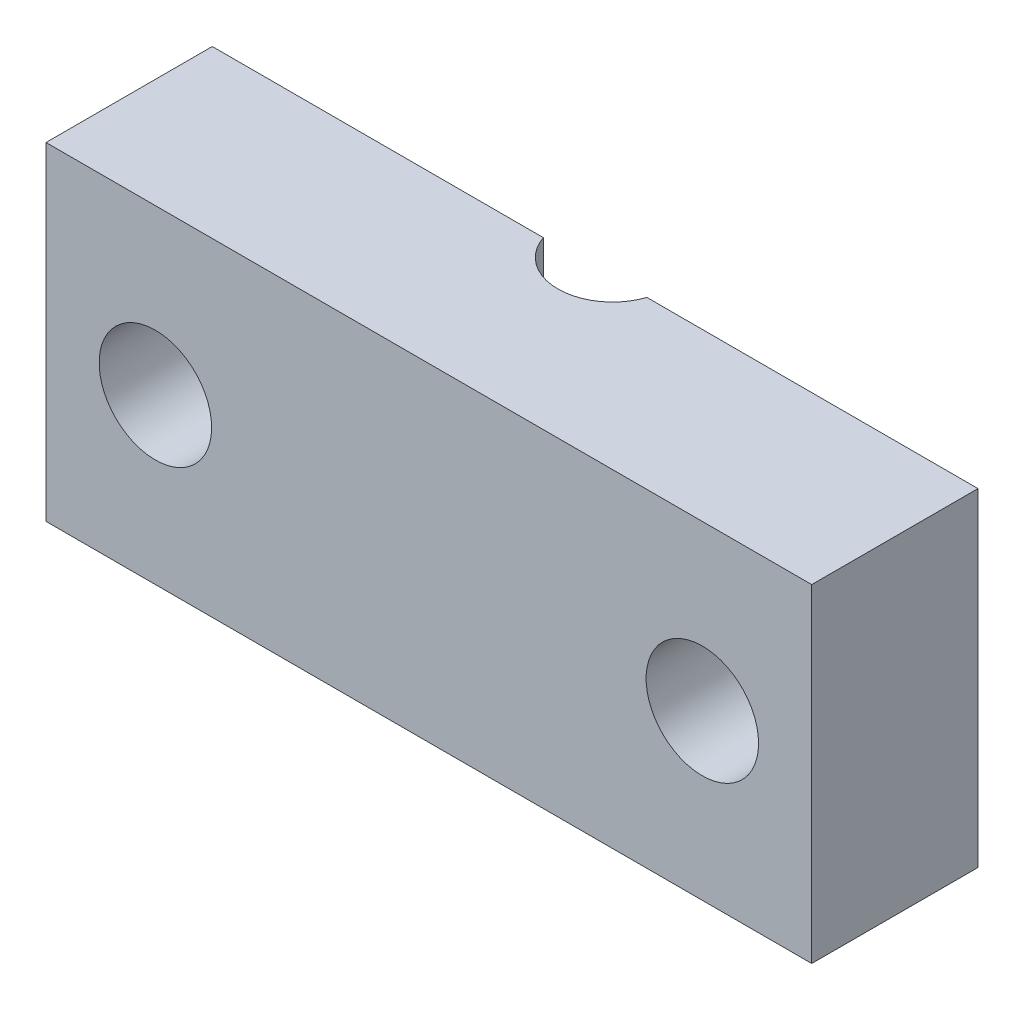
from build123d import *

# Parameters (mm, degrees)
BOSS_EXTRUDE1_DEPTH = 19.05
SKETCH2_R           = 3.2639
CUT_EXTRUDE2_DEPTH  = 11.684


with BuildPart() as part:
    # Sketch1 → Boss-Extrude1 (new body)
    with BuildSketch(Plane(origin=(0, 0, 0), x_dir=(1, 0, 0), z_dir=(0, 1, 0))):
        with BuildLine():
            Line((-28.244883355, -8.703959301), (-47.461832657, -8.703959301))
            Line((-47.461832657, -8.703959301), (-47.461832657, -18.355959301))
            Line((-47.461832657, -18.355959301), (-3.011832657, -18.355959301))
            Line((-3.011832657, -18.355959301), (-3.011832657, -8.703959301))
            Line((-3.011832657, -8.703959301), (-22.228781959, -8.703959301))
            ThreePointArc((-22.228781959, -8.703959301), (-25.236832657, -10.862959301), (-28.244883355, -8.703959301))
        make_face()
    extrude(amount=BOSS_EXTRUDE1_DEPTH)

    # Sketch2 → Cut-Extrude2 (cut)
    with BuildSketch(Plane.XY.offset(18.355959301)):
        with Locations((-41.111832657, 9.525)):
            Circle(SKETCH2_R)
        with Locations((-9.361832657, 9.525)):
            Circle(SKETCH2_R)
    extrude(amount=-CUT_EXTRUDE2_DEPTH, mode=Mode.SUBTRACT)


solid = part.part
